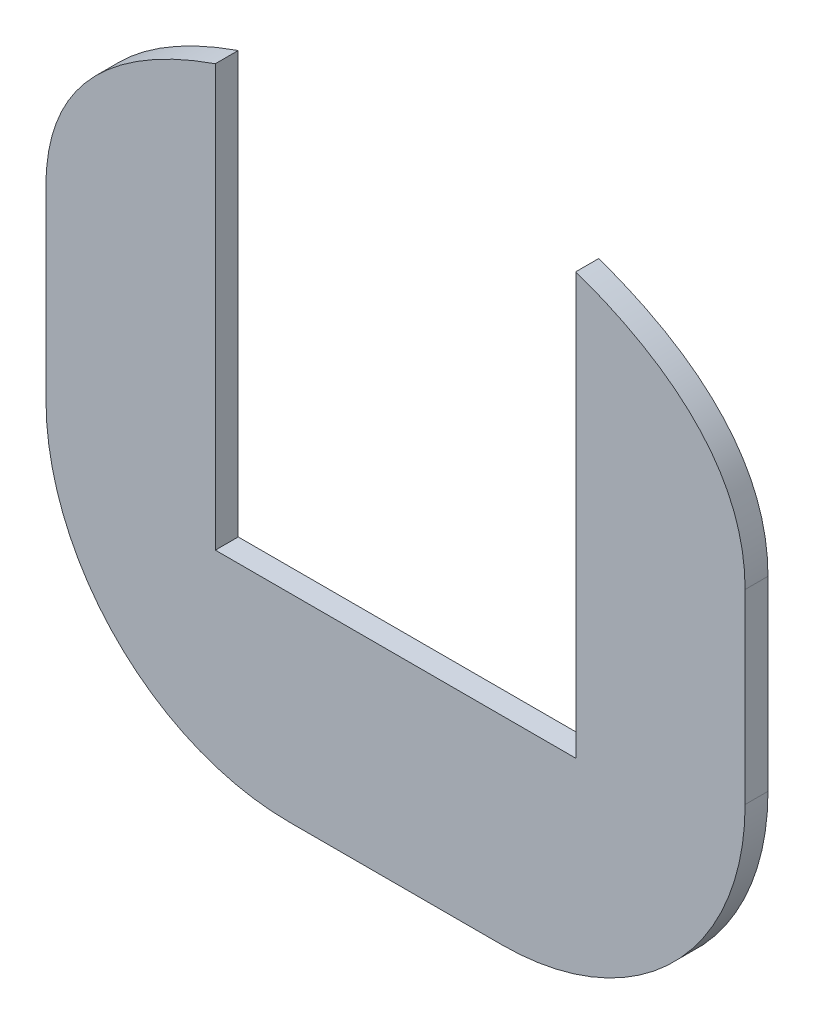
from build123d import *

# Parameters (mm, degrees)
BOSS_EXTRUDE1_DEPTH = 4.3
CUT_EXTRUDE1_DEPTH  = 10


with BuildPart() as part:
    # Sketch1 → Boss-Extrude1 (new body)
    with BuildSketch(Plane.XY):
        with BuildLine():
            Line((-20, -92.2), (-14.429475301, -92.2))
            Line((-14.429475301, -92.2), (20, -92.2))
            ThreePointArc((20, -92.2), (52.3147799, -78.8147799), (65.7, -46.5))
            Line((65.7, -46.5), (65.7, -11.5))
            add(Edge.make_bspline(
                [(65.7, -11.5), (65.7, -10.975589958), (65.677234408, -9.915490978), (65.544187041, -7.888412939), (65.220242618, -5.460671952), (64.598062769, -2.723715825), (63.478515533, 0.7162036), (61.569949009, 4.65452752), (58.553422876, 8.885275051), (54.896250473, 12.662614765), (49.30515895, 17.117750268), (41.279444306, 21.616942397), (32.802615045, 24.780729734), (26.33891585, 26.60624502), (21.797211531, 27.651780938), (17.71021827, 28.4039364), (14.808687361, 28.812738163), (12.872312778, 29.025349646), (11.633648581, 29.131856353), (10.811523275, 29.180203188), (10.282988146, 29.197593371), (10.101212389, 29.2), (10, 29.2)],
                knots=[0, 0, 0, 0, 0.015625, 0.03125, 0.0625, 0.09375, 0.125, 0.1875, 0.25, 0.3125, 0.375, 0.5, 0.625, 0.6875, 0.75, 0.8125, 0.875, 0.90625, 0.9375, 0.96875, 0.984375, 1, 1, 1, 1], degree=3))
            Line((10, 29.2), (-10, 29.2))
            add(Edge.make_bspline(
                [(-10, 29.2), (-10.101212389, 29.2), (-10.282988146, 29.197593371), (-10.811523275, 29.180203188), (-11.633648581, 29.131856353), (-12.872312778, 29.025349646), (-14.808687361, 28.812738163), (-17.71021827, 28.4039364), (-21.797211531, 27.651780938), (-26.33891585, 26.60624502), (-32.802615045, 24.780729734), (-41.279444306, 21.616942397), (-49.30515895, 17.117750268), (-54.896250473, 12.662614765), (-58.553422876, 8.885275051), (-61.569949009, 4.65452752), (-63.478515533, 0.7162036), (-64.598062769, -2.723715825), (-65.220242618, -5.460671952), (-65.544187041, -7.888412939), (-65.677234408, -9.915490978), (-65.7, -10.975589958), (-65.7, -11.5)],
                knots=[0, 0, 0, 0, 0.015625, 0.03125, 0.0625, 0.09375, 0.125, 0.1875, 0.25, 0.3125, 0.375, 0.5, 0.625, 0.6875, 0.75, 0.8125, 0.875, 0.90625, 0.9375, 0.96875, 0.984375, 1, 1, 1, 1], degree=3))
            Line((-65.7, -11.5), (-65.7, -46.5))
            ThreePointArc((-65.7, -46.5), (-52.3147799, -78.8147799), (-20, -92.2))
        make_face()
    extrude(amount=BOSS_EXTRUDE1_DEPTH)

    # Sketch2 → Cut-Extrude1 (cut)
    with BuildSketch(Plane.XY.offset(4.3)):
        Polygon((-33.87, 24.299748656), (-33.87, -54.880251344), (33.87, -54.880251344), (33.87, 24.299748656), (33.87, 35.468874446), (-33.87, 35.468874446), align=None)
    extrude(amount=-CUT_EXTRUDE1_DEPTH, mode=Mode.SUBTRACT)


solid = part.part
